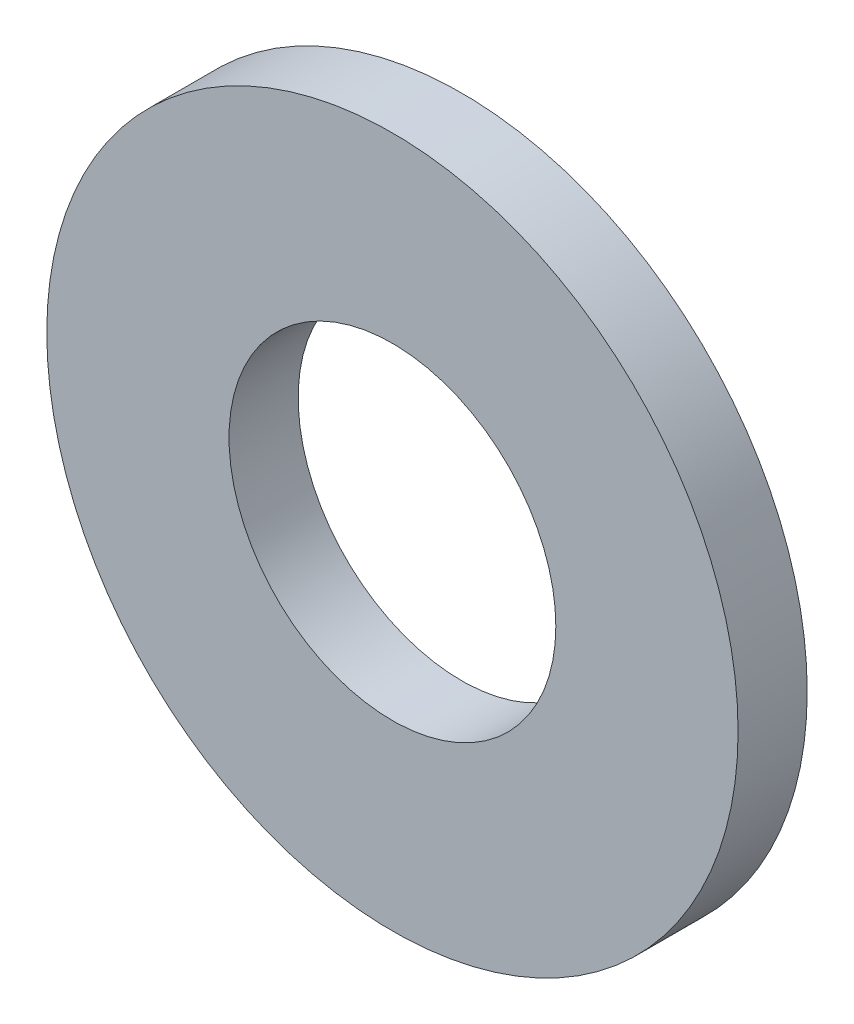
from build123d import *

# Parameters (mm, degrees)
SKETCH1_R           = 5.5
SKETCH1_R_2         = 2.6
BOSS_EXTRUDE1_DEPTH = 1.1


with BuildPart() as part:
    # Sketch1 → Boss-Extrude1 (new body)
    with BuildSketch(Plane.XY):
        Circle(SKETCH1_R)
        Circle(SKETCH1_R_2, mode=Mode.SUBTRACT)
    extrude(amount=BOSS_EXTRUDE1_DEPTH)


solid = part.part
